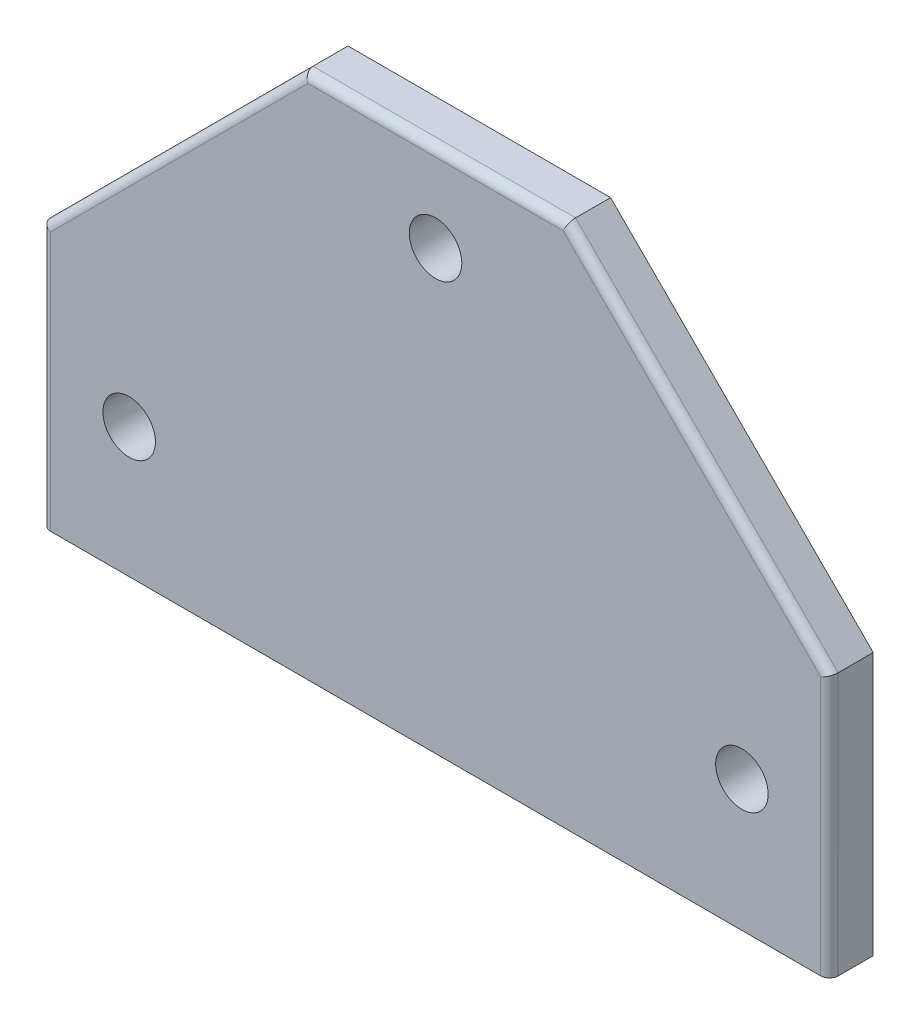
from build123d import *

# Parameters (mm, degrees)
BOSS_EXTRUDE1_DEPTH = 6.35
FILLET1_R           = 1.27
SKETCH3_R           = 3.81
CUT_EXTRUDE1_DEPTH  = 6.35


with BuildPart() as part:
    # Sketch1 → Boss-Extrude1 (new body)
    with BuildSketch(Plane.XY):
        Polygon((0, 38.1), (38.1, 76.2), (76.2, 76.2), (114.3, 38.1), (114.3, 0), (0, 0), align=None)
    extrude(amount=BOSS_EXTRUDE1_DEPTH)

    # Fillet1
    fillet1_edges = [part.edges().sort_by_distance(p)[0] for p in [
        (114.3, 19.05, 6.35),
        (95.25, 57.15, 6.35),
        (57.15, 76.2, 6.35),
        (19.05, 57.15, 6.35),
        (0, 19.05, 6.35),
    ]]
    fillet(fillet1_edges, radius=FILLET1_R)

    # Sketch3 → Cut-Extrude1 (cut)
    with BuildSketch(Plane.XY.offset(6.35)):
        with Locations((12.7, 18.813572483)):
            Circle(SKETCH3_R)
        with Locations((101.6, 19.02044656)):
            Circle(SKETCH3_R)
        with Locations((57.15, 63.5)):
            Circle(SKETCH3_R)
    extrude(amount=-CUT_EXTRUDE1_DEPTH, mode=Mode.SUBTRACT)


solid = part.part
